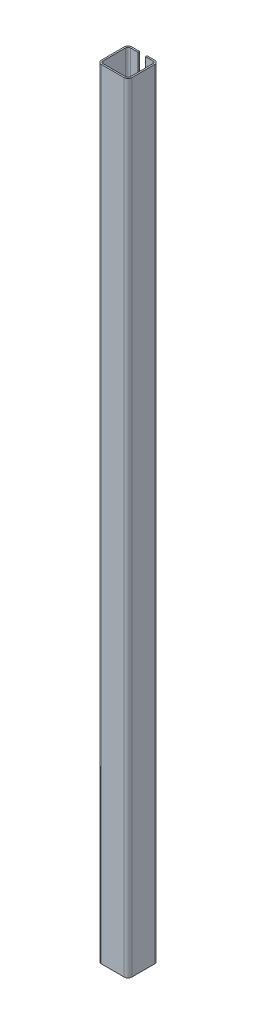
from build123d import *

# Parameters (mm, degrees)
EXTRUDE_1_DEPTH = 1025


with BuildPart() as part:
    # Эскиз1 → Вытянуть-Тонкостенный1 (new body)
    with BuildSketch(Plane(origin=(0, 0, 0), x_dir=(1, 0, 0), z_dir=(0, 1, 0))):
        with BuildLine():
            Line((-5, 40), (-15, 40))
            ThreePointArc((-15, 40), (-18.535533906, 38.535533906), (-20, 35))
            Line((-20, 35), (-20, 5))
            ThreePointArc((-20, 5), (-18.535533906, 1.464466094), (-15, 0))
            Line((-15, 0), (15, 0))
            ThreePointArc((15, 0), (18.535533906, 1.464466094), (20, 5))
            Line((20, 5), (20, 35))
            ThreePointArc((20, 35), (18.535533906, 38.535533906), (15, 40))
            Line((15, 40), (5, 40))
            Line((5, 40), (5, 38))
            Line((5, 38), (15, 38))
            ThreePointArc((15, 38), (17.121320344, 37.121320344), (18, 35))
            Line((18, 35), (18, 5))
            ThreePointArc((18, 5), (17.121320344, 2.878679656), (15, 2))
            Line((15, 2), (-15, 2))
            ThreePointArc((-15, 2), (-17.121320344, 2.878679656), (-18, 5))
            Line((-18, 5), (-18, 35))
            ThreePointArc((-18, 35), (-17.121320344, 37.121320344), (-15, 38))
            Line((-15, 38), (-5, 38))
            Line((-5, 38), (-5, 40))
        make_face()
    extrude(amount=EXTRUDE_1_DEPTH)


solid = part.part
